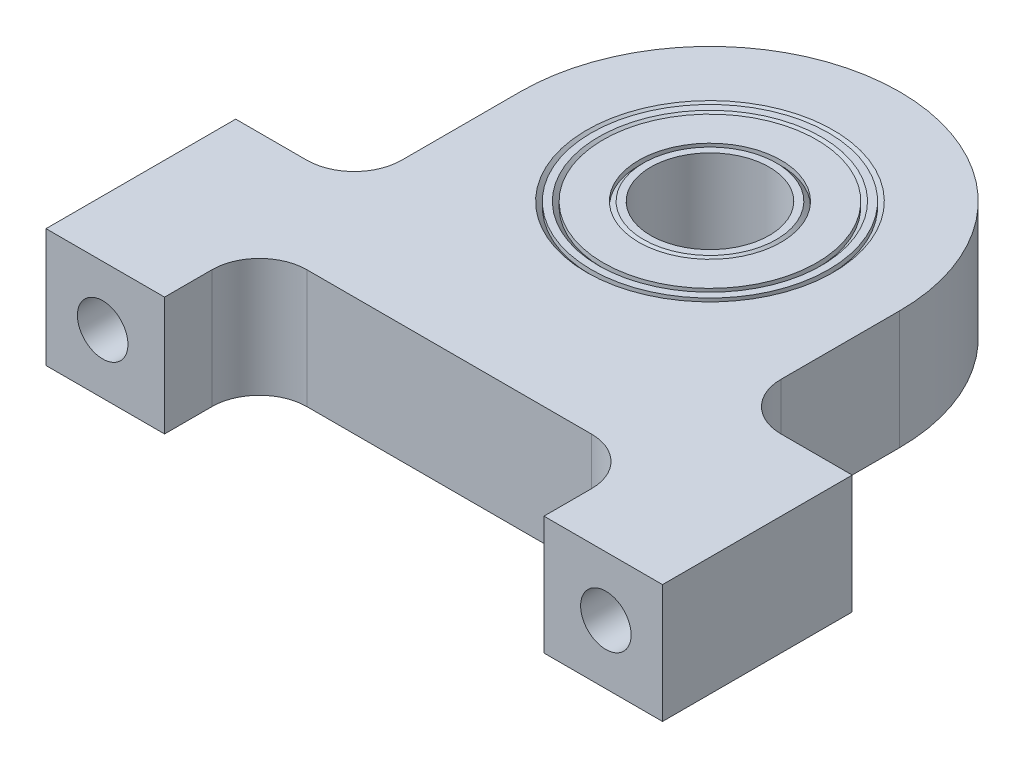
from build123d import *

# Parameters (mm, degrees)
BOSS_EXTRUDE1_DEPTH            = 6.35
SKETCH2_R                      = 6.35
CUT_EXTRUDE1_DEPTH             = 4.7625
CUT_EXTRUDE2_REACH             = 3.587
SKETCH3_R                      = 5.08
CHAMFER1_SIZE                  = 0.254
SKETCH4_R                      = 6.35
SKETCH4_R_2                    = 5.715
BOSS_EXTRUDE2_DEPTH            = 4.7625
CHAMFER2_SIZE                  = 0.254
SKETCH5_R                      = 3.81
SKETCH5_R_2                    = 3.175
BOSS_EXTRUDE3_DEPTH            = 4.7625
CHAMFER3_SIZE                  = 0.254
SKETCH7_R                      = 5.715
SKETCH7_R_2                    = 3.81
BOSS_EXTRUDE4_DEPTH            = 4.2545
F_6_32_TAPPED_HOLE1_AT_2_COUNT = 2
F_6_32_TAPPED_HOLE1_AT_2_PITCH = 26.9494


with BuildPart() as part:
    # Sketch1 → Boss-Extrude1 (new body)
    with BuildSketch(Plane(origin=(0, 0, 0), x_dir=(1, 0, 0), z_dir=(0, 1, 0))):
        with BuildLine():
            Line((-10.16, 0), (-10.16, -6.35))
            ThreePointArc((-10.16, -6.35), (-10.903948776, -8.146051224), (-12.7, -8.89))
            Line((-12.7, -8.89), (-16.51, -8.89))
            Line((-16.51, -8.89), (-16.51, -19.05))
            Line((-16.51, -19.05), (-10.16, -19.05))
            Line((-10.16, -19.05), (-10.16, -16.51))
            ThreePointArc((-10.16, -16.51), (-9.416051224, -14.713948776), (-7.62, -13.97))
            Line((-7.62, -13.97), (7.62, -13.97))
            ThreePointArc((7.62, -13.97), (9.416051224, -14.713948776), (10.16, -16.51))
            Line((10.16, -16.51), (10.16, -19.05))
            Line((10.16, -19.05), (16.51, -19.05))
            Line((16.51, -19.05), (16.51, -8.89))
            Line((16.51, -8.89), (12.7, -8.89))
            ThreePointArc((12.7, -8.89), (10.903948776, -8.146051224), (10.16, -6.35))
            Line((10.16, -6.35), (10.16, 0))
            ThreePointArc((10.16, 0), (0, 10.16), (-10.16, 0))
        make_face()
    extrude(amount=BOSS_EXTRUDE1_DEPTH)

    # Sketch2 → Cut-Extrude1 (cut)
    with BuildSketch(Plane(origin=(0, 6.35, 0), x_dir=(1, 0, 0), z_dir=(0, 1, 0))):
        Circle(SKETCH2_R)
    extrude(amount=-CUT_EXTRUDE1_DEPTH, mode=Mode.SUBTRACT)

    # Sketch3 → Cut-Extrude2 (cut, up to next)
    with BuildSketch(Plane(origin=(0, 1.5875, 0), x_dir=(1, 0, 0), z_dir=(0, 1, 0)), mode=Mode.PRIVATE) as cut_extrude2_sk1:
        Circle(SKETCH3_R)
    cut_extrude2_tool1 = extrude(cut_extrude2_sk1.sketch, amount=-CUT_EXTRUDE2_REACH, mode=Mode.PRIVATE) & part.part
    add(cut_extrude2_tool1.solids().sort_by_distance((0, 1.5875, 0))[0], mode=Mode.SUBTRACT)

    # Chamfer1
    chamfer1_edges = [part.edges().sort_by_distance(p)[0] for p in [
        (-6.35, 6.35, 0),
    ]]
    chamfer(chamfer1_edges, length=CHAMFER1_SIZE)

    # Sketch4 → Boss-Extrude2 (add)
    with BuildSketch(Plane(origin=(0, 1.5875, 0), x_dir=(1, 0, 0), z_dir=(0, 1, 0))):
        Circle(SKETCH4_R)
        Circle(SKETCH4_R_2, mode=Mode.SUBTRACT)
    extrude(amount=BOSS_EXTRUDE2_DEPTH)

    # Chamfer2
    chamfer2_edges = [part.edges().sort_by_distance(p)[0] for p in [
        (-5.715, 1.5875, 0),
        (-5.715, 6.35, 0),
    ]]
    chamfer(chamfer2_edges, length=CHAMFER2_SIZE)

    # Sketch8 → #6-32 Tapped Hole1 (revolve, cut)
    with BuildSketch(Plane(origin=(-13.4747, 3.175, 19.05), x_dir=(0, -1, 0), z_dir=(1, 0, 0))):
        Polygon((0, 0), (0, 8.43269403), (1.35255, 7.62), (1.35255, 0), align=None)
    f_6_32_tapped_hole1 = revolve(axis=Axis((-13.4747, 3.175, 25.4), (0, 0, -1)), mode=Mode.SUBTRACT)

    # #6-32 Tapped Hole1 at 2: #6-32 Tapped Hole1 ×2
    with Locations(*[(i * F_6_32_TAPPED_HOLE1_AT_2_PITCH, 0, 0) for i in range(1, F_6_32_TAPPED_HOLE1_AT_2_COUNT)]):
        add(f_6_32_tapped_hole1, mode=Mode.SUBTRACT)


with BuildPart() as body_2:
    # Sketch5 → Boss-Extrude3 (new body)
    with BuildSketch(Plane(origin=(0, 1.5875, 0), x_dir=(-1, 0, 0), z_dir=(0, 1, 0))):
        Circle(SKETCH5_R)
        Circle(SKETCH5_R_2, mode=Mode.SUBTRACT)
    extrude(amount=BOSS_EXTRUDE3_DEPTH)

    # Chamfer3
    chamfer3_edges = [body_2.edges().sort_by_distance(p)[0] for p in [
        (3.81, 1.5875, 0),
        (3.81, 6.35, 0),
    ]]
    chamfer(chamfer3_edges, length=CHAMFER3_SIZE)

    # Sketch7 → Boss-Extrude4 (add)
    with BuildSketch(Plane(origin=(0, 6.35, 0), x_dir=(-1, 0, 0), z_dir=(0, 1, 0))):
        Circle(SKETCH7_R)
        Circle(SKETCH7_R_2, mode=Mode.SUBTRACT)
    extrude(amount=-BOSS_EXTRUDE4_DEPTH)


solid = Compound([part.part, body_2.part])
